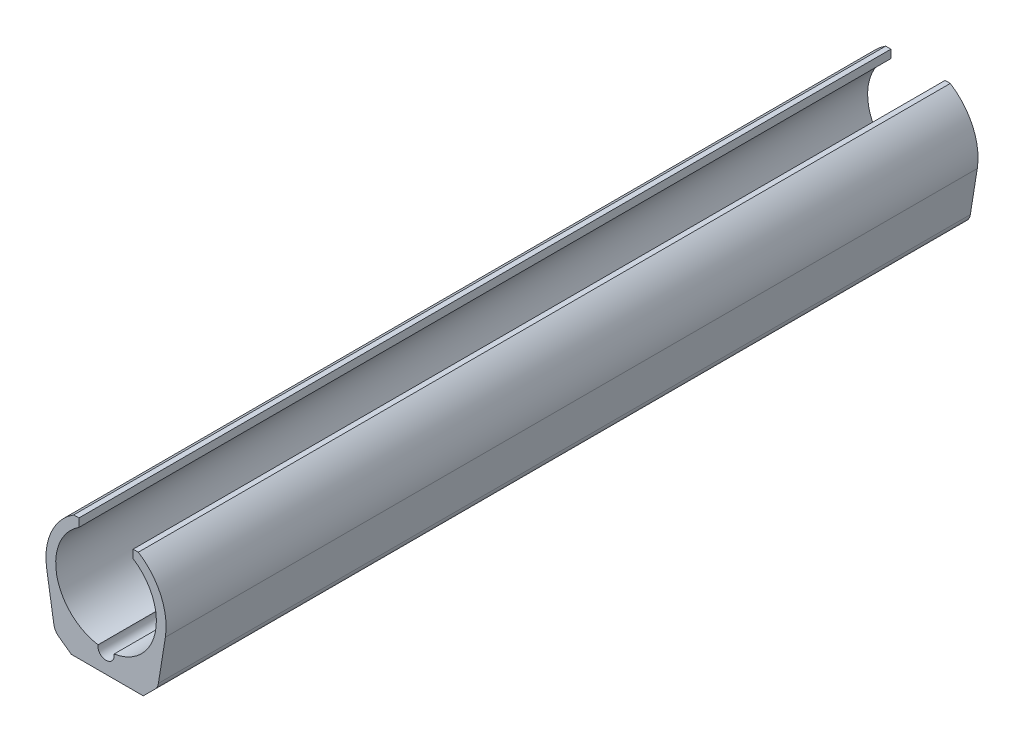
from build123d import *

# Parameters (mm, degrees)
BOSS_EXTRU_1_DEPTH      = 200
CHANFREIN1_SIZE2        = 3.618684617
CHANFREIN1_SIZE         = 3
CHANFREIN1_EDGE_2_SIZE2 = 3
CHANFREIN1_EDGE_2_SIZE  = 3.618684617
CONG_2_R                = 3


with BuildPart() as part:
    # Esquisse1 → Boss.-Extru.1 (new body)
    with BuildSketch(Plane.XY):
        with BuildLine():
            Line((-12.171180036, -17.570882511), (12.171180036, -17.570882511))
            Line((12.171180036, -17.570882511), (14.613263907, -2.343612169))
            ThreePointArc((14.613263907, -2.343612169), (13.502002072, 6.061018071), (7.960382718, 12.476870881))
            Line((7.960382718, 12.476870881), (6.669509845, 12.476870881))
            Line((6.669509845, 12.476870881), (6.669509845, 10.453594522))
            ThreePointArc((6.669509845, 10.453594522), (12.142715388, -2.512859527), (1.972784363, -12.242063627))
            ThreePointArc((1.972784363, -12.242063627), (0, -14.570882511), (-1.972784363, -12.242063627))
            ThreePointArc((-1.972784363, -12.242063627), (-12.142715388, -2.512859527), (-6.669509845, 10.453594522))
            Line((-6.669509845, 10.453594522), (-6.669509845, 12.476870881))
            Line((-6.669509845, 12.476870881), (-7.960382718, 12.476870881))
            ThreePointArc((-7.960382718, 12.476870881), (-13.502002072, 6.061018071), (-14.613263907, -2.343612169))
            Line((-14.613263907, -2.343612169), (-12.171180036, -17.570882511))
        make_face()
    extrude(amount=BOSS_EXTRU_1_DEPTH)

    # Chanfrein1
    chanfrein1_edges = [part.edges().sort_by_distance(p)[0] for p in [
        (12.171180036, -17.570882511, 100),
    ]]
    chamfer(chanfrein1_edges, length=CHANFREIN1_SIZE, length2=CHANFREIN1_SIZE2)

    # Chanfrein1 edge 2
    chanfrein1_edge_2_edges = [part.edges().sort_by_distance(p)[0] for p in [
        (-12.171180036, -17.570882511, 100),
    ]]
    chamfer(chanfrein1_edge_2_edges, length=CHANFREIN1_EDGE_2_SIZE, length2=CHANFREIN1_EDGE_2_SIZE2)

    # Congé2
    cong_2_edges = [part.edges().sort_by_distance(p)[0] for p in [
        (12.744206611, -13.997855937, 100),
        (-12.646236557, -14.608734422, 100),
    ]]
    fillet(cong_2_edges, radius=CONG_2_R)


solid = part.part
